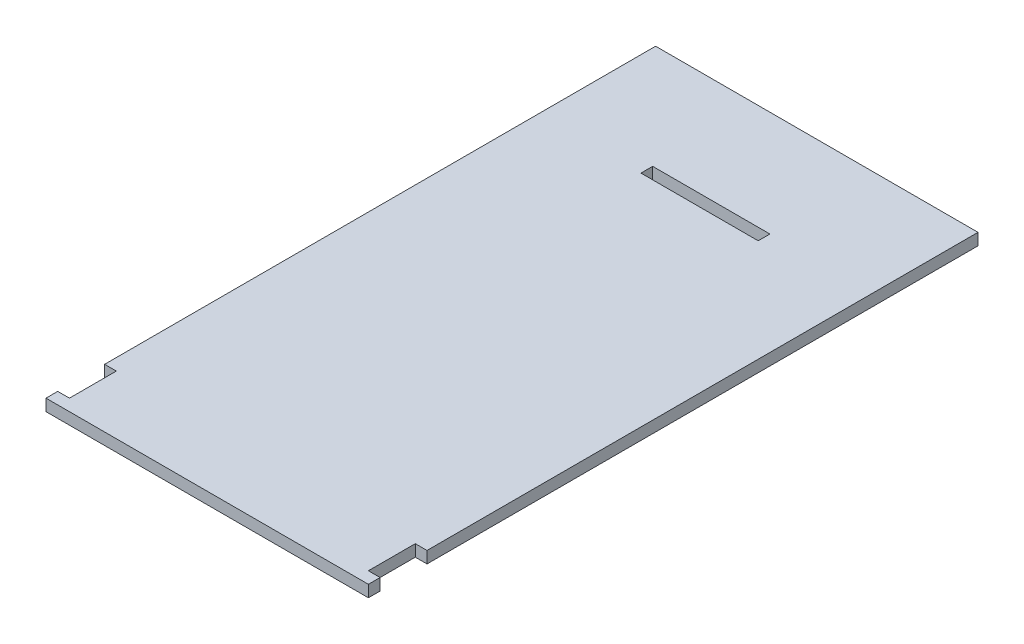
from build123d import *

# Parameters (mm, degrees)
SKETCH1_W           = 20
SKETCH1_H           = 2
BOSS_EXTRUDE1_DEPTH = 2


with BuildPart() as part:
    # Sketch1 → Boss-Extrude1 (new body)
    with BuildSketch(Plane(origin=(0, 0, 0), x_dir=(1, 0, 0), z_dir=(0, 1, 0))):
        Polygon((0, 2), (2, 2), (2, 10), (0, 10), (0, 104), (55, 104), (55, 10), (53, 10), (53, 2), (55, 2), (55, 0), (0, 0), align=None)
        with Locations((27.5, 85)):
            Rectangle(SKETCH1_W, SKETCH1_H, mode=Mode.SUBTRACT)
    extrude(amount=BOSS_EXTRUDE1_DEPTH)


solid = part.part
